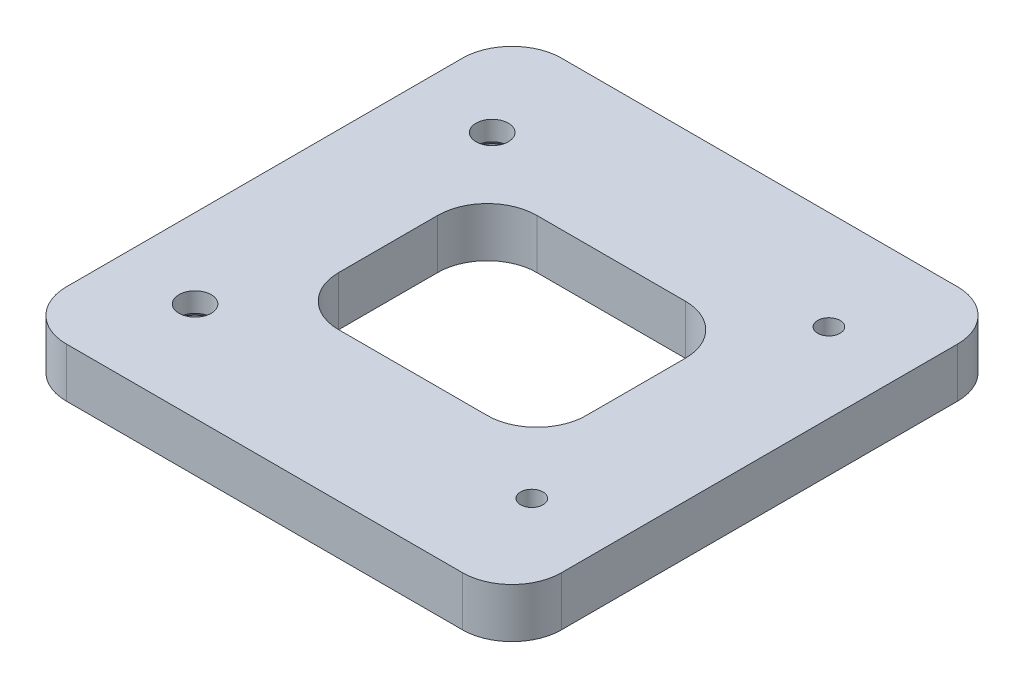
from build123d import *

# Parameters (mm, degrees)
SKETCH1_W                                 = 50
SKETCH1_H                                 = 50
BOSS_EXTRUDE1_DEPTH                       = 2.5
F_4_40_TAPPED_HOLE1_D                     = 2.2606
F_4_40_TAPPED_HOLE1_DEPTH                 = 5
CSK_FOR_4_FLAT_HEAD_MACHINE_SCREW_2_COUNT = 2
CSK_FOR_4_FLAT_HEAD_MACHINE_SCREW_2_PITCH = 30
CUT_EXTRUDE1_REACH                        = 7
SKETCH6_W                                 = 25
SKETCH6_H                                 = 20
FILLET1_R                                 = 5


with BuildPart() as part:
    # Sketch1 → Boss-Extrude1 (new body, symmetric)
    with BuildSketch(Plane(origin=(0, 0, 0), x_dir=(1, 0, 0), z_dir=(0, 1, 0))):
        Rectangle(SKETCH1_W, SKETCH1_H)
    extrude(amount=BOSS_EXTRUDE1_DEPTH, both=True)

    # #4-40 Tapped Hole1
    with Locations(Plane(origin=(0, 2.5, 0), x_dir=(1, 0, 0), z_dir=(0, 1, 0))):
        with Locations((17, 15), (17, -15)):
            Hole(F_4_40_TAPPED_HOLE1_D / 2, depth=F_4_40_TAPPED_HOLE1_DEPTH)

    # Sketch5 → CSK for #4 Flat Head Machine Screw (100)1 (revolve, cut)
    with BuildSketch(Plane(origin=(-17, -2.5, -15), x_dir=(0, 0, -1), z_dir=(1, 0, 0))):
        Polygon((0, 0), (0, 5), (1.63195, 5), (1.63195, 3.028350774), (2.857490729, 2), (2.857490729, 0), align=None)
    csk_for_4_flat_head_machine_screw_100 = revolve(axis=Axis((-17, -8.85, -15), (0, 1, 0)), mode=Mode.SUBTRACT)

    # CSK for _4 Flat Head Machine Screw _ 2: CSK for #4 Flat Head Machine Screw (100)1 ×2
    with Locations(*[(0, 0, i * CSK_FOR_4_FLAT_HEAD_MACHINE_SCREW_2_PITCH) for i in range(1, CSK_FOR_4_FLAT_HEAD_MACHINE_SCREW_2_COUNT)]):
        add(csk_for_4_flat_head_machine_screw_100, mode=Mode.SUBTRACT)

    # Sketch6 → Cut-Extrude1 (cut, up to next)
    with BuildSketch(Plane(origin=(0, 2.5, 0), x_dir=(1, 0, 0), z_dir=(0, 1, 0)), mode=Mode.PRIVATE) as cut_extrude1_sk1:
        Rectangle(SKETCH6_W, SKETCH6_H)
    cut_extrude1_tool1 = extrude(cut_extrude1_sk1.sketch, amount=-CUT_EXTRUDE1_REACH, mode=Mode.PRIVATE) & part.part
    add(cut_extrude1_tool1.solids().sort_by_distance((0, 2.5, 0))[0], mode=Mode.SUBTRACT)

    # Fillet1
    fillet1_edges = [part.edges().sort_by_distance(p)[0] for p in [
        (12.5, 0, -10),
        (12.5, 0, 10),
        (-12.5, 0, 10),
        (-12.5, 0, -10),
        (-25, 0, -25),
        (25, 0, -25),
        (25, 0, 25),
        (-25, 0, 25),
    ]]
    fillet(fillet1_edges, radius=FILLET1_R)


solid = part.part
